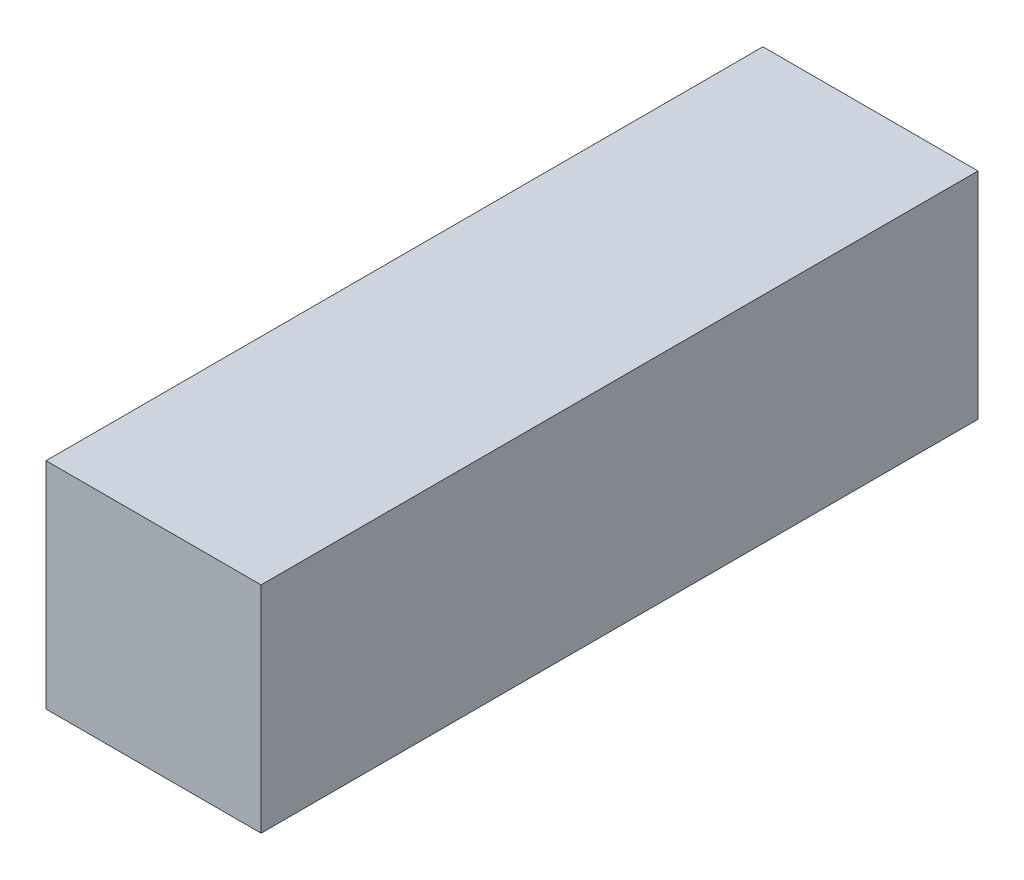
from build123d import *

# Parameters (mm, degrees)
ESQUISSE1_W      = 18
ESQUISSE1_H      = 18
EXTRUSION1_DEPTH = 60


with BuildPart() as part:
    # Esquisse1 → Extrusion1 (new body)
    with BuildSketch(Plane.XY):
        with Locations((9, 9)):
            Rectangle(ESQUISSE1_W, ESQUISSE1_H)
    extrude(amount=-EXTRUSION1_DEPTH)


solid = part.part
